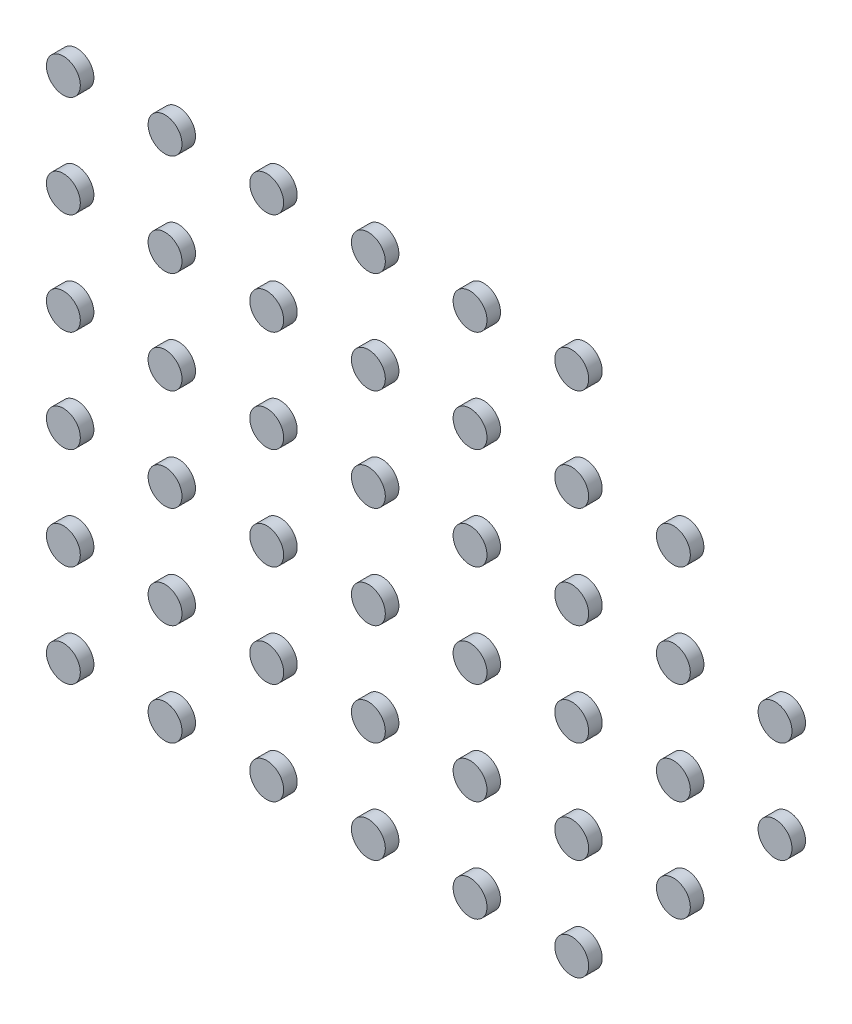
from build123d import *

# Parameters (mm, degrees)
SKETCH_1_R         = 0.5
EXTRUDE_1_DEPTH    = 0.4
EXTRUDE_1_2_DEPTH  = 0.4
EXTRUDE_1_3_DEPTH  = 0.4
EXTRUDE_1_4_DEPTH  = 0.4
EXTRUDE_1_5_DEPTH  = 0.4
EXTRUDE_1_6_DEPTH  = 0.4
EXTRUDE_1_7_DEPTH  = 0.4
EXTRUDE_1_8_DEPTH  = 0.4
EXTRUDE_1_9_DEPTH  = 0.4
EXTRUDE_1_10_DEPTH = 0.4
EXTRUDE_1_11_DEPTH = 0.4
EXTRUDE_1_12_DEPTH = 0.4
EXTRUDE_1_13_DEPTH = 0.4
EXTRUDE_1_14_DEPTH = 0.4
EXTRUDE_1_15_DEPTH = 0.4
EXTRUDE_1_16_DEPTH = 0.4
EXTRUDE_1_17_DEPTH = 0.4
EXTRUDE_1_18_DEPTH = 0.4
EXTRUDE_1_19_DEPTH = 0.4
EXTRUDE_1_20_DEPTH = 0.4
EXTRUDE_1_21_DEPTH = 0.4
EXTRUDE_1_22_DEPTH = 0.4
EXTRUDE_1_23_DEPTH = 0.4
EXTRUDE_1_24_DEPTH = 0.4
EXTRUDE_1_25_DEPTH = 0.4
EXTRUDE_1_26_DEPTH = 0.4
EXTRUDE_1_27_DEPTH = 0.4
EXTRUDE_1_28_DEPTH = 0.4
EXTRUDE_1_29_DEPTH = 0.4
EXTRUDE_1_30_DEPTH = 0.4
EXTRUDE_1_31_DEPTH = 0.4
EXTRUDE_1_32_DEPTH = 0.4
EXTRUDE_1_33_DEPTH = 0.4
EXTRUDE_1_34_DEPTH = 0.4
EXTRUDE_1_35_DEPTH = 0.4
EXTRUDE_1_36_DEPTH = 0.4
EXTRUDE_1_37_DEPTH = 0.4
EXTRUDE_1_38_DEPTH = 0.4
EXTRUDE_1_39_DEPTH = 0.4
EXTRUDE_1_40_DEPTH = 0.4
EXTRUDE_1_41_DEPTH = 0.4
EXTRUDE_1_42_DEPTH = 0.4


with BuildPart() as part:
    # 草图1 → 凸台-拉伸1 (new body)
    with BuildSketch(Plane.XY):
        with Locations((-4.5, 1.5)):
            Circle(SKETCH_1_R)
    extrude(amount=EXTRUDE_1_DEPTH)


with BuildPart() as body_2:
    # 草图1 → Extrude 1 2 (new body)
    with BuildSketch(Plane.XY):
        with Locations((-1.5, 1.5)):
            Circle(SKETCH_1_R)
    extrude(amount=EXTRUDE_1_2_DEPTH)


with BuildPart() as body_3:
    # 草图1 → Extrude 1 3 (new body)
    with BuildSketch(Plane.XY):
        with Locations((1.5, 1.5)):
            Circle(SKETCH_1_R)
    extrude(amount=EXTRUDE_1_3_DEPTH)


with BuildPart() as body_4:
    # 草图1 → Extrude 1 4 (new body)
    with BuildSketch(Plane.XY):
        with Locations((4.5, 1.5)):
            Circle(SKETCH_1_R)
    extrude(amount=EXTRUDE_1_4_DEPTH)


with BuildPart() as body_5:
    # 草图1 → Extrude 1 5 (new body)
    with BuildSketch(Plane.XY):
        with Locations((7.5, 1.5)):
            Circle(SKETCH_1_R)
    extrude(amount=EXTRUDE_1_5_DEPTH)


with BuildPart() as body_6:
    # 草图1 → Extrude 1 6 (new body)
    with BuildSketch(Plane.XY):
        with Locations((10.5, 1.5)):
            Circle(SKETCH_1_R)
    extrude(amount=EXTRUDE_1_6_DEPTH)


with BuildPart() as body_7:
    # 草图1 → Extrude 1 7 (new body)
    with BuildSketch(Plane.XY):
        with Locations((10.5, -1.5)):
            Circle(SKETCH_1_R)
    extrude(amount=EXTRUDE_1_7_DEPTH)


with BuildPart() as body_8:
    # 草图1 → Extrude 1 8 (new body)
    with BuildSketch(Plane.XY):
        with Locations((7.5, -1.5)):
            Circle(SKETCH_1_R)
    extrude(amount=EXTRUDE_1_8_DEPTH)


with BuildPart() as body_9:
    # 草图1 → Extrude 1 9 (new body)
    with BuildSketch(Plane.XY):
        with Locations((-10.5, 7.5)):
            Circle(SKETCH_1_R)
    extrude(amount=EXTRUDE_1_9_DEPTH)


with BuildPart() as body_10:
    # 草图1 → Extrude 1 10 (new body)
    with BuildSketch(Plane.XY):
        with Locations((-1.5, 7.5)):
            Circle(SKETCH_1_R)
    extrude(amount=EXTRUDE_1_10_DEPTH)


with BuildPart() as body_11:
    # 草图1 → Extrude 1 11 (new body)
    with BuildSketch(Plane.XY):
        with Locations((1.5, 7.5)):
            Circle(SKETCH_1_R)
    extrude(amount=EXTRUDE_1_11_DEPTH)


with BuildPart() as body_12:
    # 草图1 → Extrude 1 12 (new body)
    with BuildSketch(Plane.XY):
        with Locations((4.5, 7.5)):
            Circle(SKETCH_1_R)
    extrude(amount=EXTRUDE_1_12_DEPTH)


with BuildPart() as body_13:
    # 草图1 → Extrude 1 13 (new body)
    with BuildSketch(Plane.XY):
        with Locations((-10.5, 1.5)):
            Circle(SKETCH_1_R)
    extrude(amount=EXTRUDE_1_13_DEPTH)


with BuildPart() as body_14:
    # 草图1 → Extrude 1 14 (new body)
    with BuildSketch(Plane.XY):
        with Locations((-10.5, 4.5)):
            Circle(SKETCH_1_R)
    extrude(amount=EXTRUDE_1_14_DEPTH)


with BuildPart() as body_15:
    # 草图1 → Extrude 1 15 (new body)
    with BuildSketch(Plane.XY):
        with Locations((-10.5, -1.5)):
            Circle(SKETCH_1_R)
    extrude(amount=EXTRUDE_1_15_DEPTH)


with BuildPart() as body_16:
    # 草图1 → Extrude 1 16 (new body)
    with BuildSketch(Plane.XY):
        with Locations((-10.5, -4.5)):
            Circle(SKETCH_1_R)
    extrude(amount=EXTRUDE_1_16_DEPTH)


with BuildPart() as body_17:
    # 草图1 → Extrude 1 17 (new body)
    with BuildSketch(Plane.XY):
        with Locations((-10.5, -7.5)):
            Circle(SKETCH_1_R)
    extrude(amount=EXTRUDE_1_17_DEPTH)


with BuildPart() as body_18:
    # 草图1 → Extrude 1 18 (new body)
    with BuildSketch(Plane.XY):
        with Locations((-7.5, -7.5)):
            Circle(SKETCH_1_R)
    extrude(amount=EXTRUDE_1_18_DEPTH)


with BuildPart() as body_19:
    # 草图1 → Extrude 1 19 (new body)
    with BuildSketch(Plane.XY):
        with Locations((-7.5, -4.5)):
            Circle(SKETCH_1_R)
    extrude(amount=EXTRUDE_1_19_DEPTH)


with BuildPart() as body_20:
    # 草图1 → Extrude 1 20 (new body)
    with BuildSketch(Plane.XY):
        with Locations((-7.5, -1.5)):
            Circle(SKETCH_1_R)
    extrude(amount=EXTRUDE_1_20_DEPTH)


with BuildPart() as body_21:
    # 草图1 → Extrude 1 21 (new body)
    with BuildSketch(Plane.XY):
        with Locations((-7.5, 1.5)):
            Circle(SKETCH_1_R)
    extrude(amount=EXTRUDE_1_21_DEPTH)


with BuildPart() as body_22:
    # 草图1 → Extrude 1 22 (new body)
    with BuildSketch(Plane.XY):
        with Locations((-7.5, 4.5)):
            Circle(SKETCH_1_R)
    extrude(amount=EXTRUDE_1_22_DEPTH)


with BuildPart() as body_23:
    # 草图1 → Extrude 1 23 (new body)
    with BuildSketch(Plane.XY):
        with Locations((-4.5, 4.5)):
            Circle(SKETCH_1_R)
    extrude(amount=EXTRUDE_1_23_DEPTH)


with BuildPart() as body_24:
    # 草图1 → Extrude 1 24 (new body)
    with BuildSketch(Plane.XY):
        with Locations((-1.5, 4.5)):
            Circle(SKETCH_1_R)
    extrude(amount=EXTRUDE_1_24_DEPTH)


with BuildPart() as body_25:
    # 草图1 → Extrude 1 25 (new body)
    with BuildSketch(Plane.XY):
        with Locations((1.5, 4.5)):
            Circle(SKETCH_1_R)
    extrude(amount=EXTRUDE_1_25_DEPTH)


with BuildPart() as body_26:
    # 草图1 → Extrude 1 26 (new body)
    with BuildSketch(Plane.XY):
        with Locations((7.5, 4.5)):
            Circle(SKETCH_1_R)
    extrude(amount=EXTRUDE_1_26_DEPTH)


with BuildPart() as body_27:
    # 草图1 → Extrude 1 27 (new body)
    with BuildSketch(Plane.XY):
        with Locations((1.5, -1.5)):
            Circle(SKETCH_1_R)
    extrude(amount=EXTRUDE_1_27_DEPTH)


with BuildPart() as body_28:
    # 草图1 → Extrude 1 28 (new body)
    with BuildSketch(Plane.XY):
        with Locations((-1.5, -1.5)):
            Circle(SKETCH_1_R)
    extrude(amount=EXTRUDE_1_28_DEPTH)


with BuildPart() as body_29:
    # 草图1 → Extrude 1 29 (new body)
    with BuildSketch(Plane.XY):
        with Locations((-4.5, -1.5)):
            Circle(SKETCH_1_R)
    extrude(amount=EXTRUDE_1_29_DEPTH)


with BuildPart() as body_30:
    # 草图1 → Extrude 1 30 (new body)
    with BuildSketch(Plane.XY):
        with Locations((-4.5, -4.5)):
            Circle(SKETCH_1_R)
    extrude(amount=EXTRUDE_1_30_DEPTH)


with BuildPart() as body_31:
    # 草图1 → Extrude 1 31 (new body)
    with BuildSketch(Plane.XY):
        with Locations((-1.5, -4.5)):
            Circle(SKETCH_1_R)
    extrude(amount=EXTRUDE_1_31_DEPTH)


with BuildPart() as body_32:
    # 草图1 → Extrude 1 32 (new body)
    with BuildSketch(Plane.XY):
        with Locations((-4.5, -7.5)):
            Circle(SKETCH_1_R)
    extrude(amount=EXTRUDE_1_32_DEPTH)


with BuildPart() as body_33:
    # 草图1 → Extrude 1 33 (new body)
    with BuildSketch(Plane.XY):
        with Locations((-1.5, -7.5)):
            Circle(SKETCH_1_R)
    extrude(amount=EXTRUDE_1_33_DEPTH)


with BuildPart() as body_34:
    # 草图1 → Extrude 1 34 (new body)
    with BuildSketch(Plane.XY):
        with Locations((1.5, -7.5)):
            Circle(SKETCH_1_R)
    extrude(amount=EXTRUDE_1_34_DEPTH)


with BuildPart() as body_35:
    # 草图1 → Extrude 1 35 (new body)
    with BuildSketch(Plane.XY):
        with Locations((4.5, -7.5)):
            Circle(SKETCH_1_R)
    extrude(amount=EXTRUDE_1_35_DEPTH)


with BuildPart() as body_36:
    # 草图1 → Extrude 1 36 (new body)
    with BuildSketch(Plane.XY):
        with Locations((4.5, -4.5)):
            Circle(SKETCH_1_R)
    extrude(amount=EXTRUDE_1_36_DEPTH)


with BuildPart() as body_37:
    # 草图1 → Extrude 1 37 (new body)
    with BuildSketch(Plane.XY):
        with Locations((7.5, -4.5)):
            Circle(SKETCH_1_R)
    extrude(amount=EXTRUDE_1_37_DEPTH)


with BuildPart() as body_38:
    # 草图1 → Extrude 1 38 (new body)
    with BuildSketch(Plane.XY):
        with Locations((4.5, -1.5)):
            Circle(SKETCH_1_R)
    extrude(amount=EXTRUDE_1_38_DEPTH)


with BuildPart() as body_39:
    # 草图1 → Extrude 1 39 (new body)
    with BuildSketch(Plane.XY):
        with Locations((-7.5, 7.5)):
            Circle(SKETCH_1_R)
    extrude(amount=EXTRUDE_1_39_DEPTH)


with BuildPart() as body_40:
    # 草图1 → Extrude 1 40 (new body)
    with BuildSketch(Plane.XY):
        with Locations((-4.5, 7.5)):
            Circle(SKETCH_1_R)
    extrude(amount=EXTRUDE_1_40_DEPTH)


with BuildPart() as body_41:
    # 草图1 → Extrude 1 41 (new body)
    with BuildSketch(Plane.XY):
        with Locations((4.5, 4.5)):
            Circle(SKETCH_1_R)
    extrude(amount=EXTRUDE_1_41_DEPTH)


with BuildPart() as body_42:
    # 草图1 → Extrude 1 42 (new body)
    with BuildSketch(Plane.XY):
        with Locations((1.5, -4.5)):
            Circle(SKETCH_1_R)
    extrude(amount=EXTRUDE_1_42_DEPTH)


solid = Compound([part.part, body_2.part, body_3.part, body_4.part, body_5.part, body_6.part, body_7.part, body_8.part, body_9.part, body_10.part, body_11.part, body_12.part, body_13.part, body_14.part, body_15.part, body_16.part, body_17.part, body_18.part, body_19.part, body_20.part, body_21.part, body_22.part, body_23.part, body_24.part, body_25.part, body_26.part, body_27.part, body_28.part, body_29.part, body_30.part, body_31.part, body_32.part, body_33.part, body_34.part, body_35.part, body_36.part, body_37.part, body_38.part, body_39.part, body_40.part, body_41.part, body_42.part])
